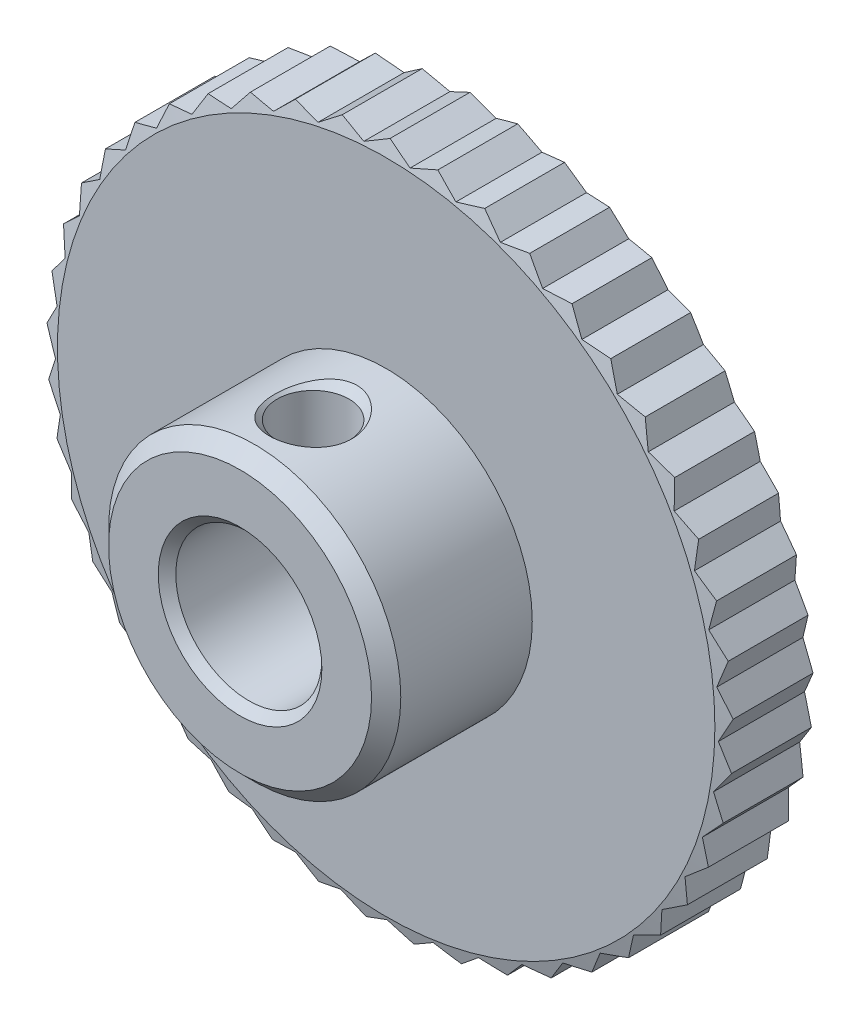
from build123d import *

# Parameters (mm, degrees)
SKETCH2_R          = 23.5
CUT_EXTRUDE1_DEPTH = 3


with BuildPart() as part:
    # Sketch1 → Revolve1 (revolve)
    with BuildSketch(Plane(origin=(0, 0, 0), x_dir=(0, 0, -1), z_dir=(1, 0, 0))):
        Polygon((-8, 2.8), (-7.7, 2.5), (-0.3, 2.5), (0, 2.8), (0, 11.25), (-0.401923789, 12.75), (-2.598076211, 12.75), (-3, 11.25), (-3, 5), (-7.5, 5), (-8, 4.5), align=None)
    revolve(axis=Axis((0, 0, 0), (0, 0, 1)))

    # Sketch2 → Cut-Extrude1 (cut)
    with BuildSketch(Plane.XY):
        Circle(SKETCH2_R)
        Polygon((-11.742842217, 0.410069086), (-11.343085887, -0.396109288), (-11.685632271, -1.228209443), (-11.177567997, -1.970906817), (-11.400974784, -2.842582273), (-10.79449146, -3.507342886), (-10.894410291, -4.401627473), (-10.201312425, -4.975512516), (-10.175798494, -5.875), (-9.409576448, -6.346839454), (-9.259126355, -7.234022335), (-8.434693769, -7.594632382), (-8.162235853, -8.452242654), (-7.29563937, -8.694604429), (-6.906476714, -9.505949684), (-6.014583649, -9.625345891), (-5.516290863, -10.374634216), (-4.616460899, -10.368740944), (-4.018736684, -11.041388294), (-3.128483989, -10.910320249), (-2.442962367, -11.493234309), (-1.579614696, -11.23954258), (-0.819638566, -11.721377591), (0, -11.35), (0.819638566, -11.721377591), (1.579614696, -11.23954258), (2.442962367, -11.493234309), (3.128483989, -10.910320249), (4.018736684, -11.041388294), (4.616460899, -10.368740944), (5.516290863, -10.374634216), (6.014583649, -9.625345891), (6.906476714, -9.505949684), (7.29563937, -8.694604429), (8.162235853, -8.452242654), (8.434693769, -7.594632382), (9.259126355, -7.234022335), (9.409576448, -6.346839454), (10.175798494, -5.875), (10.201312425, -4.975512516), (10.894410291, -4.401627473), (10.79449146, -3.507342886), (11.400974784, -2.842582273), (11.177567997, -1.970906817), (11.685632271, -1.228209443), (11.343085887, -0.396109288), (11.742842217, 0.410069086), (11.287823512, 1.186398058), (11.571491098, 2.040366088), (11.012856493, 2.745813515), (11.174914066, 3.630949684), (10.523536749, 4.251784835), (10.560830044, 5.150860975), (9.829388333, 5.675), (9.741191478, 6.570516616), (8.943922053, 6.987757745), (8.731951699, 7.862284625), (7.884372505, 8.164506734), (7.552754414, 9.001022207), (6.671362614, 9.182342886), (6.226551355, 9.96456513), (5.328502238, 10.021455179), (4.779155556, 10.734159127), (3.881928627, 10.665511246), (3.238738931, 11.294824927), (2.359797691, 11.101975268), (1.635283936, 11.635649808), (0.791735977, 11.32235197), (0, 11.75), (-0.791735977, 11.32235197), (-1.635283936, 11.635649808), (-2.359797691, 11.101975268), (-3.238738931, 11.294824927), (-3.881928627, 10.665511246), (-4.779155556, 10.734159127), (-5.328502238, 10.021455179), (-6.226551355, 9.96456513), (-6.671362614, 9.182342886), (-7.552754414, 9.001022207), (-7.884372505, 8.164506734), (-8.731951699, 7.862284625), (-8.943922053, 6.987757745), (-9.741191478, 6.570516616), (-9.829388333, 5.675), (-10.560830044, 5.150860975), (-10.523536749, 4.251784835), (-11.174914066, 3.630949684), (-11.012856493, 2.745813515), (-11.571491098, 2.040366088), (-11.287823512, 1.186398058), align=None, mode=Mode.SUBTRACT)
    extrude(amount=CUT_EXTRUDE1_DEPTH, mode=Mode.SUBTRACT)

    # Sketch3 → Cut-Revolve1 (revolve, cut)
    with BuildSketch(Plane.XY.offset(5.5)):
        Polygon((0, 0), (-1.5, 0), (-1.5, 2.5), (-1.2295, 2.7705), (-1.2295, 4.7295), (-1.5, 5), (-1.5, 10), (0, 10), align=None)
    revolve(axis=Axis((0, 10, 5.5), (0, -1, 0)), mode=Mode.SUBTRACT)


solid = part.part
